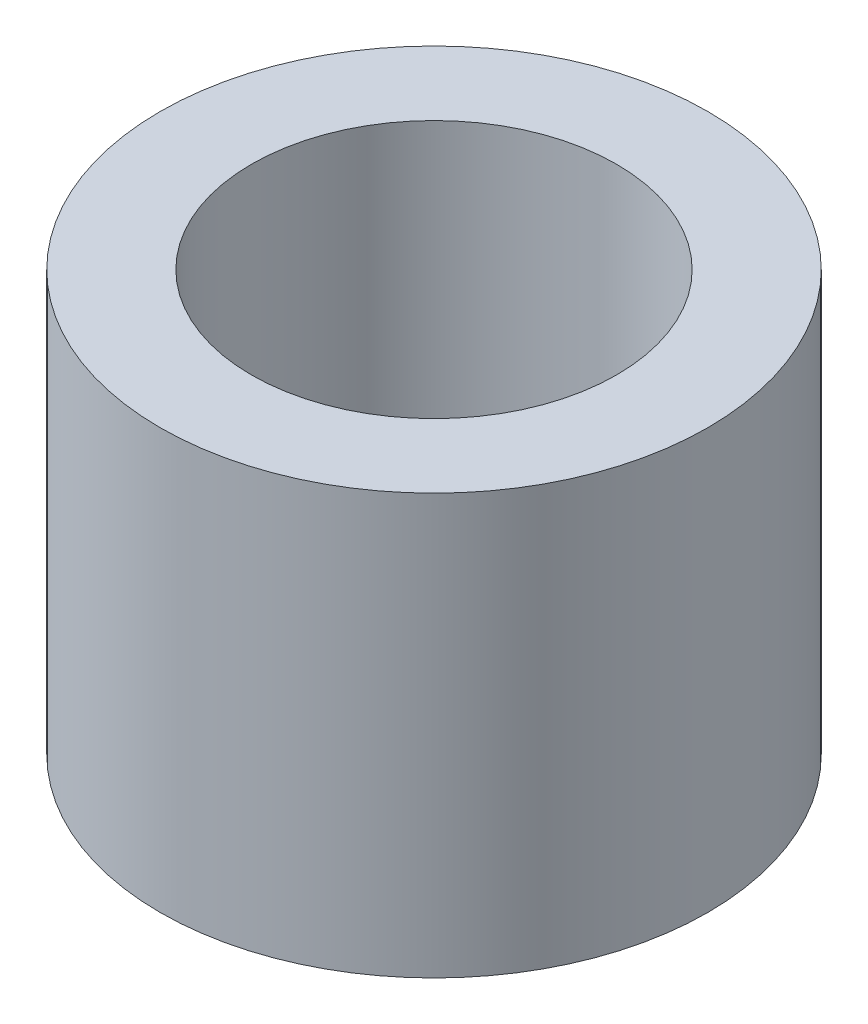
from build123d import *

# Parameters (mm, degrees)
SKETCH1_R      = 0.75
SKETCH1_R_2    = 0.5
EXTRUDE1_DEPTH = 0.575


with BuildPart() as part:
    # Sketch1 → Extrude1 (new body, symmetric)
    with BuildSketch(Plane(origin=(0, 0, 0), x_dir=(1, 0, 0), z_dir=(0, 1, 0))):
        with Locations(Location((0, 0, 0), (0, 0, 270))):  # turned: the seam where the file's is
            Circle(SKETCH1_R)
        with Locations(Location((0, 0, 0), (0, 0, 270))):  # turned: the seam where the file's is
            Circle(SKETCH1_R_2, mode=Mode.SUBTRACT)
    extrude(amount=EXTRUDE1_DEPTH, both=True)


solid = part.part
